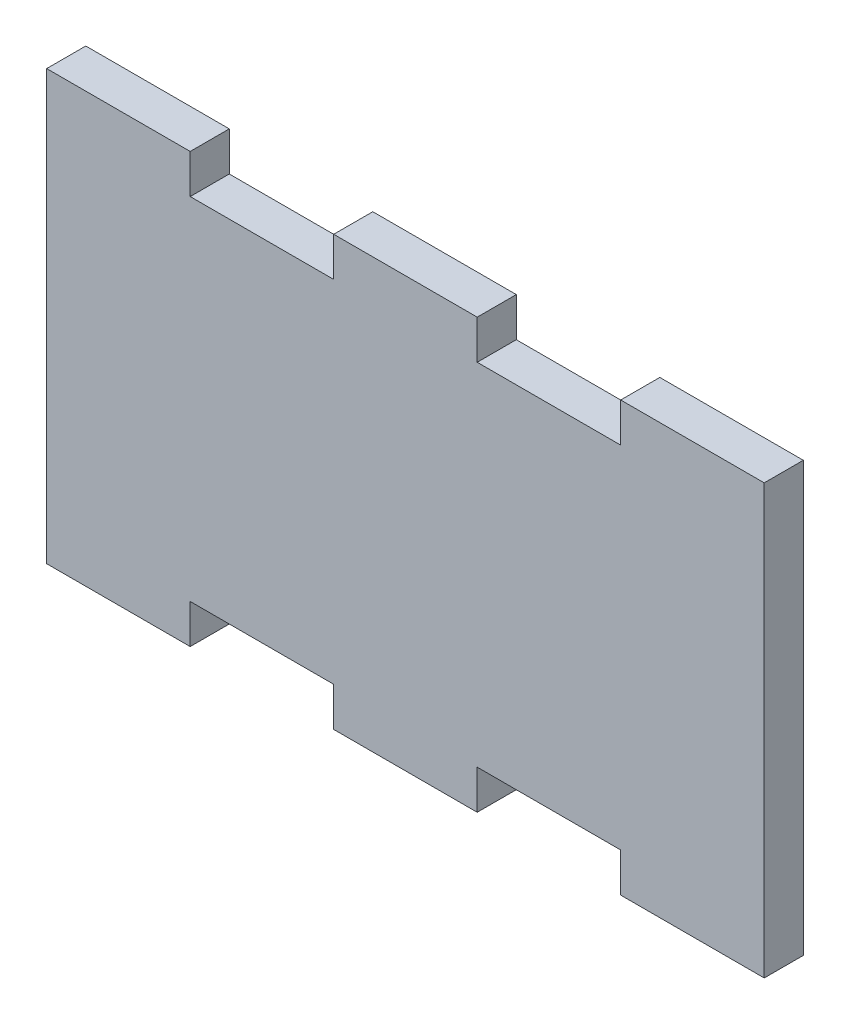
from build123d import *

# Parameters (mm, degrees)
BOSS_EXTRUDE1_DEPTH = 3.175


with BuildPart() as part:
    # Sketch1 → Boss-Extrude1 (new body)
    with BuildSketch(Plane.XY):
        Polygon((0, 0), (29.14, 0), (29.14, 14.24), (29.14, 17.415), (23.312, 17.415), (23.312, 14.24), (11.656, 14.24), (11.656, 17.415), (0, 17.415), (0, 14.24), align=None)
    extrude(amount=BOSS_EXTRUDE1_DEPTH)

    # Mirror1: part across plane


with BuildPart() as part_1:
    add(part.part)
    add(part.part.mirror(Plane(origin=(0, 0, 3.175), x_dir=(0, 0, 1), z_dir=(0, 1, 0))))

    # Mirror3: part across plane


with BuildPart() as part_2:
    add(part_1.part)
    add(part_1.part.mirror(Plane(origin=(29.14, 14.24, 3.175), x_dir=(0, 0, 1), z_dir=(-1, 0, 0))))


solid = part_2.part
